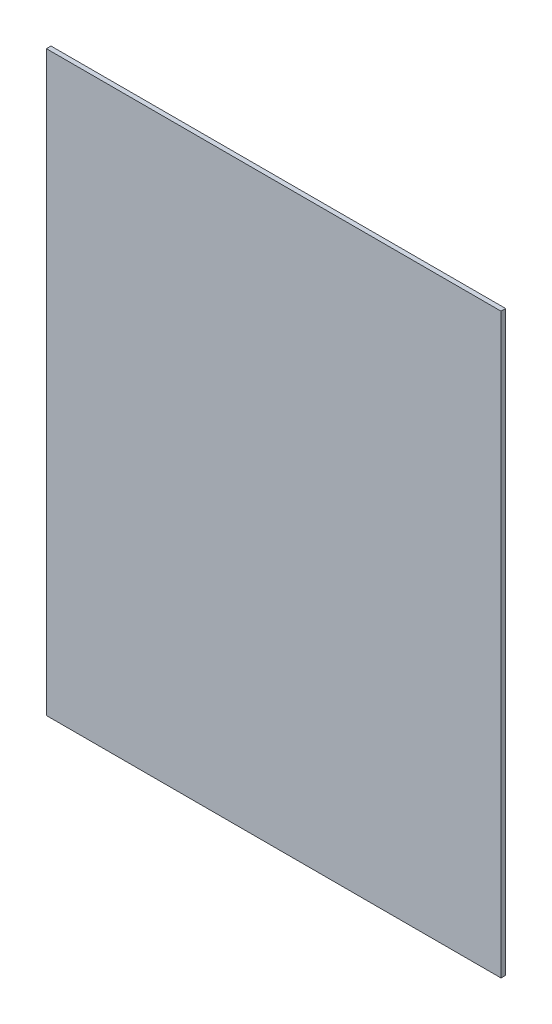
from build123d import *

# Parameters (mm, degrees)
SKETCH1_W           = 74
SKETCH1_H           = 94
BOSS_EXTRUDE1_DEPTH = 0.75


with BuildPart() as part:
    # Sketch1 → Boss-Extrude1 (new body)
    with BuildSketch(Plane.XY):
        with Locations((0, 52.5)):
            Rectangle(SKETCH1_W, SKETCH1_H)
    extrude(amount=BOSS_EXTRUDE1_DEPTH)


solid = part.part
